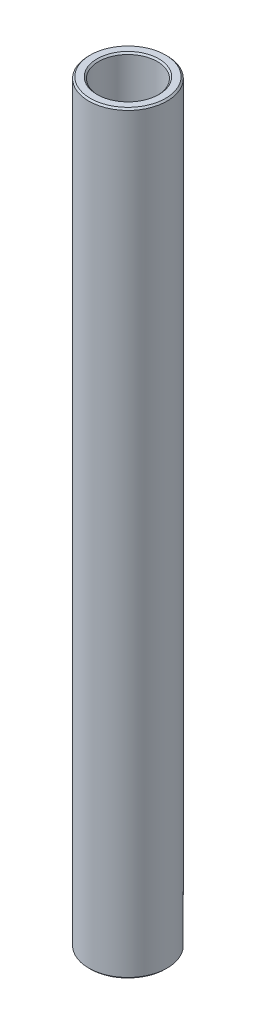
from build123d import *

# Parameters (mm, degrees)
SKETCH1_W     = 1.5875
SKETCH1_H     = 122.2375
CHAMFER1_SIZE = 0.254


with BuildPart() as part:
    # Sketch1 → Revolve1 (revolve)
    with BuildSketch(Plane.XY):
        with Locations((64.810346068, -377.497848385)):
            Rectangle(SKETCH1_W, SKETCH1_H)
    revolve(axis=Axis((59.254096068, -448.141598385, 0), (0, 1, 0)))

    # Chamfer1
    chamfer1_edges = [part.edges().sort_by_distance(p)[0] for p in [
        (52.904096068, -438.616598385, 0),
        (52.904096068, -316.379098385, 0),
        (54.491596068, -316.379098385, 0),
        (54.491596068, -438.616598385, 0),
    ]]
    chamfer(chamfer1_edges, length=CHAMFER1_SIZE)


solid = part.part
